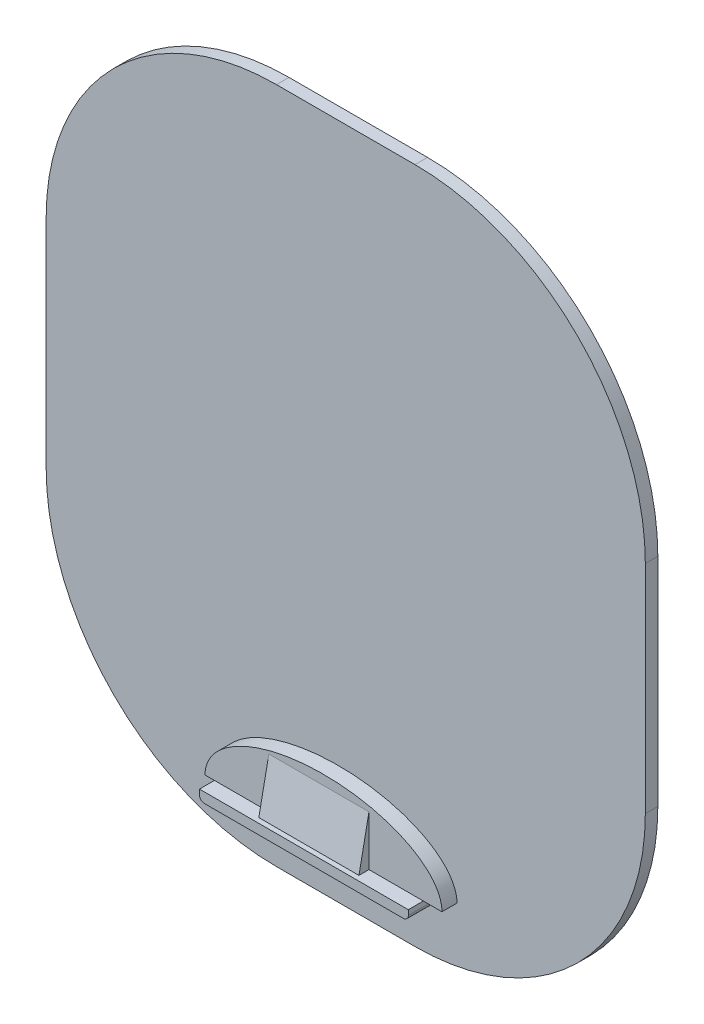
from build123d import *

# Parameters (mm, degrees)
BOSS_EXTRUDE3_DEPTH = 6.35
BOSS_EXTRUDE4_DEPTH = 7.62
BOSS_EXTRUDE5_DEPTH = 15.24
GUSSET1_THICKNESS   = 50.8


with BuildPart() as part:
    # Sketch14 → Boss-Extrude3 (new body)
    with BuildSketch(Plane.XY.offset(8.89)):
        with BuildLine():
            Line((198.236322144, 213.469330483), (127.925881088, 213.469330483))
            ThreePointArc((127.925881088, 213.469330483), (45.307524774, 179.247686797), (11.085881088, 96.629330483))
            Line((11.085881088, 96.629330483), (11.085881088, -13.285692494))
            ThreePointArc((11.085881088, -13.285692494), (45.307524774, -95.904048808), (127.925881088, -130.125692494))
            Line((127.925881088, -130.125692494), (198.236322144, -130.125692494))
            ThreePointArc((198.236322144, -130.125692494), (280.854678457, -95.904048808), (315.076322144, -13.285692494))
            Line((315.076322144, -13.285692494), (315.076322144, 96.629330483))
            ThreePointArc((315.076322144, 96.629330483), (280.854678457, 179.247686797), (198.236322144, 213.469330483))
        make_face()
    extrude(amount=BOSS_EXTRUDE3_DEPTH)

    # Sketch15 → Boss-Extrude4 (add)
    with BuildSketch(Plane.XY.offset(15.24)):
        with BuildLine():
            Line((99.311309815, -100.359196716), (219.521518968, -100.359196716))
            add(Edge.make_bspline(
                [(219.521518968, -100.359196716), (219.521518968, -69.99464543), (159.416414392, -69.99464543), (99.311309815, -69.99464543), (99.311309815, -100.359196716)],
                knots=[3.141592654, 3.141592654, 3.141592654, 4.71238898, 4.71238898, 6.283185307, 6.283185307, 6.283185307], degree=2, weights=[1, 0.707106781, 1, 0.707106781, 1]))
        make_face()
    extrude(amount=BOSS_EXTRUDE4_DEPTH)

    # Sketch15_3 → Boss-Extrude5 (add)
    with BuildSketch(Plane.XY.offset(15.24)):
        with BuildLine():
            Line((210.069251259, -100.359196716), (104.100842418, -100.359196716))
            Line((104.100842418, -100.359196716), (104.100842418, -102.899196716))
            ThreePointArc((104.100842418, -102.899196716), (104.844791194, -104.69524794), (106.640842418, -105.439196716))
            Line((106.640842418, -105.439196716), (207.529251259, -105.439196716))
            ThreePointArc((207.529251259, -105.439196716), (209.325302483, -104.69524794), (210.069251259, -102.899196716))
            Line((210.069251259, -102.899196716), (210.069251259, -100.359196716))
        make_face()
    extrude(amount=BOSS_EXTRUDE5_DEPTH)


with BuildPart() as body_2:
    # Gusset1: a gusset: a plate 50.8 thick in the corner of two members, its outline drawn in place
    gusset1_outline = Wire([Line((182.485046839, -100.359196716, 22.86), (182.485046839, -74.959196716, 22.86)), Line((182.485046839, -74.959196716, 22.86), (182.485046839, -100.359196716, 27.94)), Line((182.485046839, -100.359196716, 27.94), (182.485046839, -100.359196716, 22.86))])
    add(extrude(Face(gusset1_outline), amount=GUSSET1_THICKNESS, dir=(-1, 0, 0)))


solid = Compound([part.part, body_2.part])
